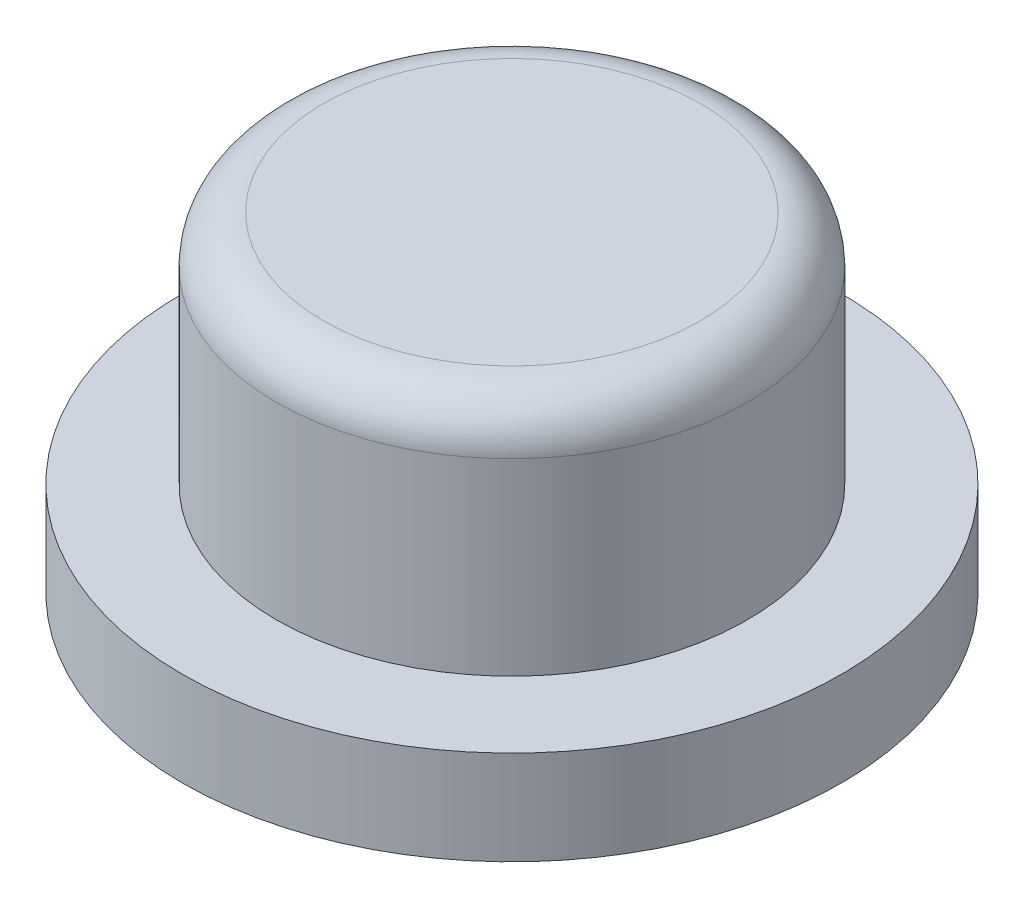
from build123d import *

# Parameters (mm, degrees)
SKETCH_1_R          = 7
EXTRUDE_1_DEPTH     = 2
SKETCH_2_R          = 5
EXTRUDE_2_DEPTH     = 5
SKETCH_3_R          = 2.5
CUT_EXTRUDE_1_DEPTH = 5
FILLET_1_R          = 1


with BuildPart() as part:
    # 草图1 → 凸台-拉伸1 (new body)
    with BuildSketch(Plane(origin=(0, 0, 0), x_dir=(1, 0, 0), z_dir=(0, 1, 0))):
        Circle(SKETCH_1_R)
    extrude(amount=EXTRUDE_1_DEPTH)

    # 草图2 → 凸台-拉伸2 (add)
    with BuildSketch(Plane(origin=(0, 2, 0), x_dir=(1, 0, 0), z_dir=(0, 1, 0))):
        Circle(SKETCH_2_R)
    extrude(amount=EXTRUDE_2_DEPTH)

    # 草图3 → 切除-拉伸1 (cut)
    with BuildSketch(Plane.XZ):
        Circle(SKETCH_3_R)
    extrude(amount=-CUT_EXTRUDE_1_DEPTH, mode=Mode.SUBTRACT)

    # 圆角1
    fillet_1_edges = [part.edges().sort_by_distance(p)[0] for p in [
        (-5, 7, 0),
    ]]
    fillet(fillet_1_edges, radius=FILLET_1_R)


solid = part.part
